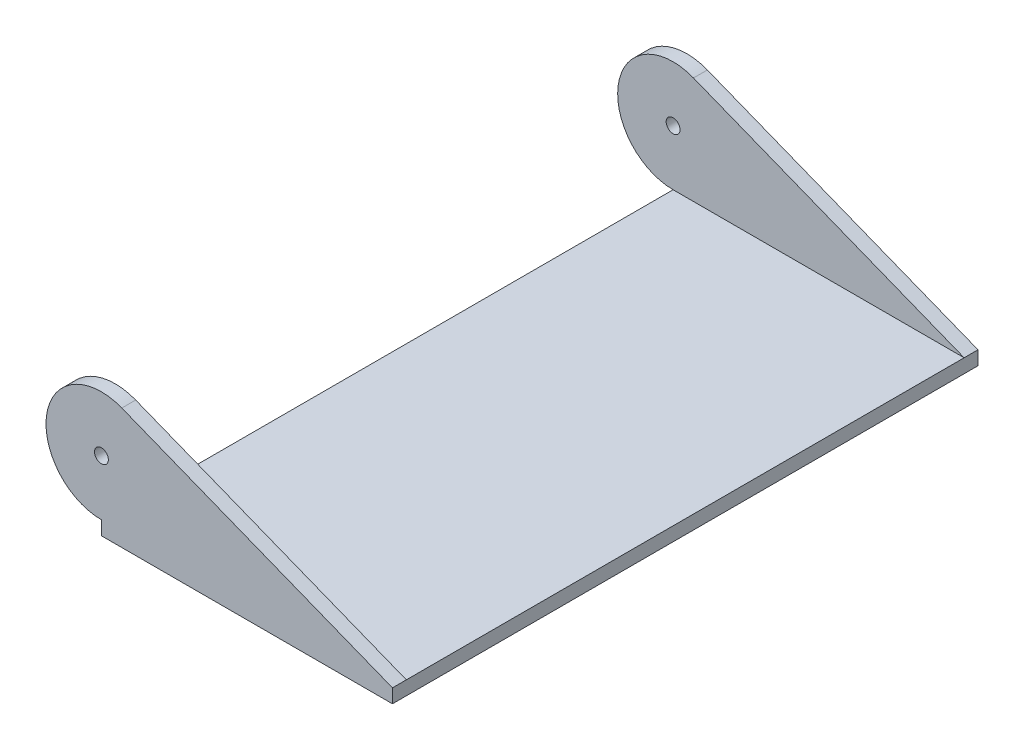
from build123d import *

# Parameters (mm, degrees)
SKETCH2_W           = 33.3375
SKETCH2_H           = 67.071875
BOSS_EXTRUDE1_DEPTH = 1.5875
SKETCH3_R           = 0.79375
BOSS_EXTRUDE2_DEPTH = 67.071875
SKETCH4_W           = 63.896875
SKETCH4_H           = 12.7
CUT_EXTRUDE1_DEPTH  = 40.6875


with BuildPart() as part:
    # Sketch2 → Boss-Extrude1 (new body)
    with BuildSketch(Plane(origin=(0, 0, 0), x_dir=(1, 0, 0), z_dir=(0, 1, 0))):
        with Locations((-8.563888889, 50.797800926)):
            Rectangle(SKETCH2_W, SKETCH2_H)
    extrude(amount=BOSS_EXTRUDE1_DEPTH)

    # Sketch3 → Boss-Extrude2 (add)
    with BuildSketch(Plane.XY.offset(-17.261863426)):
        with BuildLine():
            Line((-25.232638889, 1.5875), (8.104861111, 1.5875))
            Line((8.104861111, 1.5875), (-22.898284403, 13.84286105))
            ThreePointArc((-22.898284403, 13.84286105), (-31.470488786, 9.125661885), (-25.232638889, 1.5875))
        make_face()
        with Locations((-25.232638889, 7.9375)):
            Circle(SKETCH3_R, mode=Mode.SUBTRACT)
    extrude(amount=-BOSS_EXTRUDE2_DEPTH)

    # Sketch4 → Cut-Extrude1 (cut, through all)
    with BuildSketch(Plane(origin=(8.104861111, 0, 0), x_dir=(0, 0, -1), z_dir=(1, 0, 0))):
        with Locations((50.797800926, 7.9375)):
            Rectangle(SKETCH4_W, SKETCH4_H)
    extrude(amount=-CUT_EXTRUDE1_DEPTH, mode=Mode.SUBTRACT)


solid = part.part
